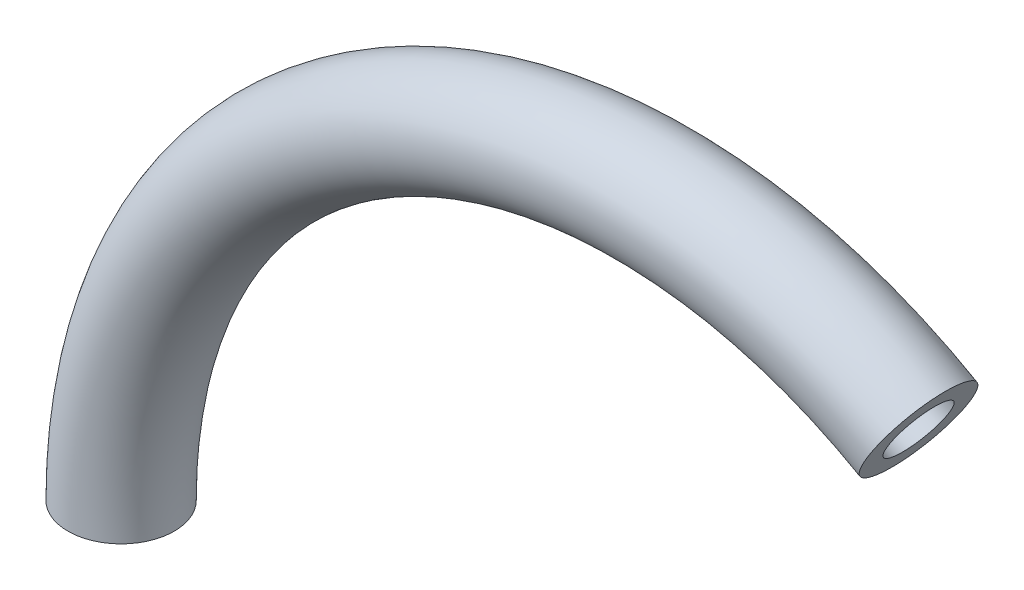
from build123d import *

# Parameters (mm, degrees)
SKETCH1_R = 6.35
SHELL1_T  = -2.54


with BuildPart() as part:
    # Sweep1: sweep along a path in Sketch2
    with BuildLine(Plane.XY) as sweep1_path:
        ThreePointArc((-63.5, 0), (-31.75, 54.99261314), (31.75, 54.99261314))
    # Sketch1 → Sweep1 (sweep)
    with BuildSketch(Plane(origin=(0, 0, 0), x_dir=(1, 0, 0), z_dir=(0, 1, 0))):
        with Locations((-63.5, 0)):
            Circle(SKETCH1_R)
    sweep(path=sweep1_path.line)

    # Shell1
    shell1_openings = [part.faces().sort_by_distance(p)[0] for p in [
        (31.75, 54.99261314, 0),
        (-63.5, 0, 0),
    ]]
    offset(amount=SHELL1_T, openings=shell1_openings, kind=Kind.INTERSECTION)


solid = part.part
